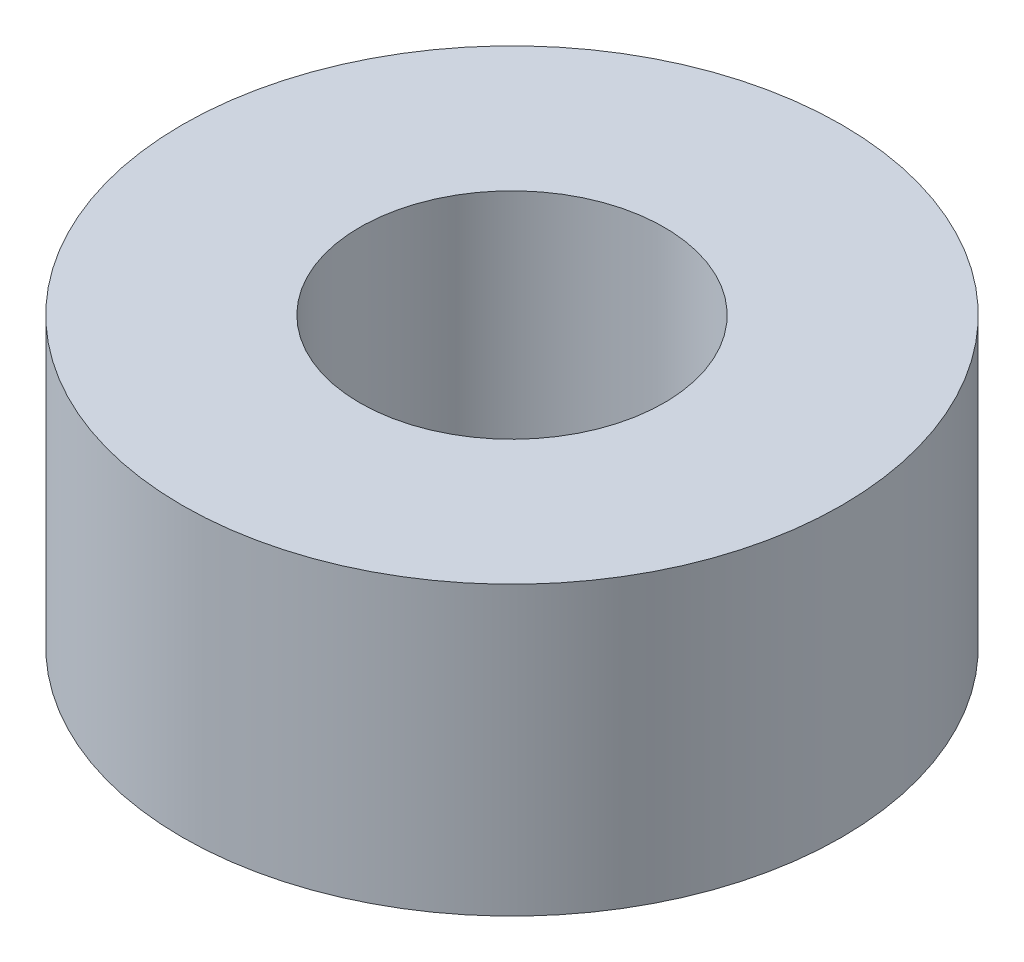
from build123d import *

# Parameters (mm, degrees)
SKETCH1_R           = 1.95
SKETCH1_R_2         = 0.9
BOSS_EXTRUDE1_DEPTH = 1.7


with BuildPart() as part:
    # Sketch1 → Boss-Extrude1 (new body)
    with BuildSketch(Plane(origin=(0, 0, 0), x_dir=(1, 0, 0), z_dir=(0, 1, 0))):
        Circle(SKETCH1_R)
        Circle(SKETCH1_R_2, mode=Mode.SUBTRACT)
    extrude(amount=BOSS_EXTRUDE1_DEPTH)


solid = part.part
